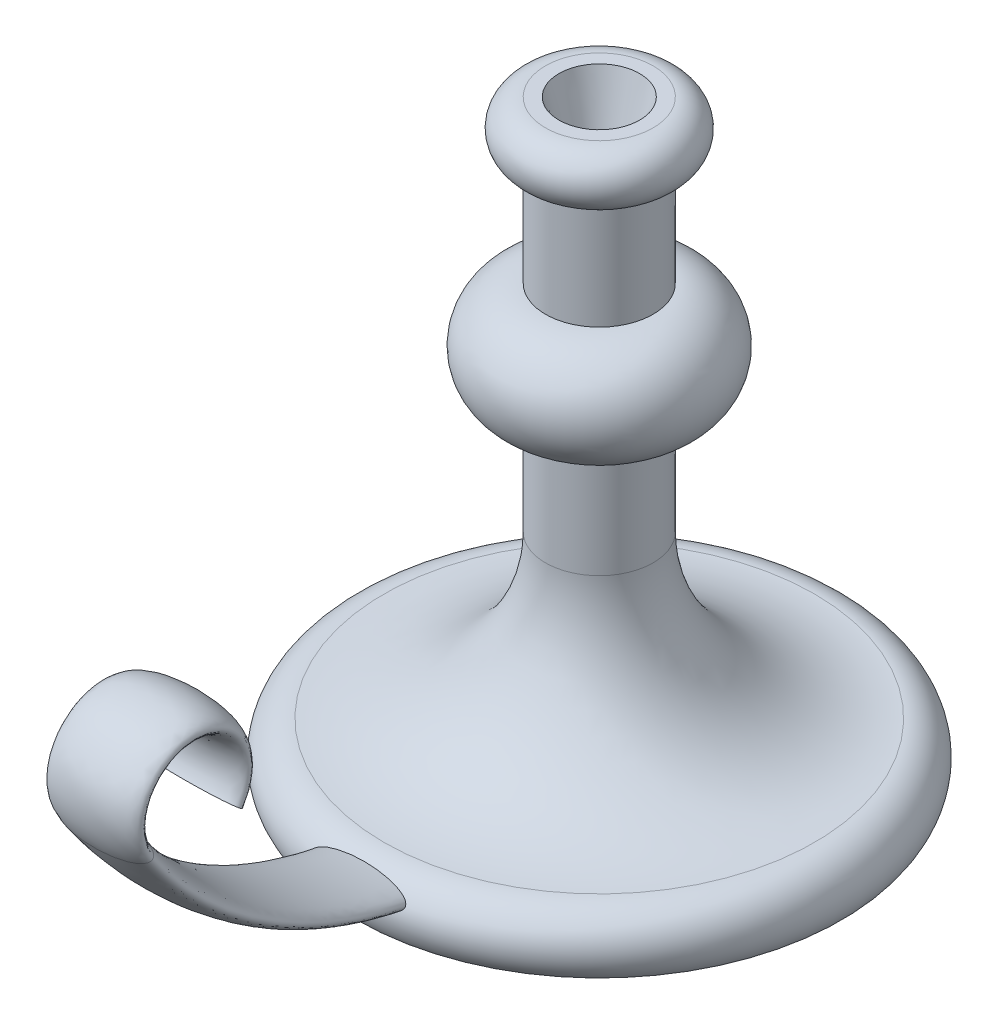
from build123d import *

# Parameters (mm, degrees)
SKETCH9_RX         = 17.5
SKETCH9_RY         = 5
SKETCH18_R         = 15
CUT_EXTRUDE1_DEPTH = 25
CUT_EXTRUDE1_TAPER = 15


with BuildPart() as part:
    # Sketch3 → Revolve1 (revolve)
    with BuildSketch(Plane.XY):
        with BuildLine():
            Line((0, 0), (0, 220))
            Line((0, 220), (20, 220))
            ThreePointArc((20, 220), (30, 210), (20, 200))
            Line((20, 200), (20, 160))
            ThreePointArc((20, 160), (40, 140), (20, 120))
            Line((20, 120), (20, 80))
            ThreePointArc((20, 80), (37.573593129, 37.573593129), (80, 20))
            ThreePointArc((80, 20), (91.180339887, 13.090169944), (90, 0))
            Line((90, 0), (0, 0))
        make_face()
    revolve(axis=Axis((0, 0, 0), (0, 1, 0)))

    # Sweep2: sweep along a path in Sketch8
    with BuildLine(Plane(origin=(0, 0, 0), x_dir=(0, 0, -1), z_dir=(1, 0, 0))) as sweep2_path:
        Line((0, 10), (-60, 10))
        ThreePointArc((-60, 10), (-129.821200219, 27.240819526), (-183.592070943, 75))
        ThreePointArc((-183.592070943, 75), (-167.113128151, 106.333333333), (-150.634185358, 75))
    # Sketch9 → Sweep2 (sweep)
    with BuildSketch(Plane.XY):
        with Locations((0, 10)):
            Ellipse(SKETCH9_RX, SKETCH9_RY)
    sweep(path=sweep2_path.line)

    # Sketch18 → Cut-Extrude1 (cut)
    with BuildSketch(Plane(origin=(0, 220, 0), x_dir=(1, 0, 0), z_dir=(0, 1, 0))):
        Circle(SKETCH18_R)
    extrude(amount=-CUT_EXTRUDE1_DEPTH, taper=CUT_EXTRUDE1_TAPER, mode=Mode.SUBTRACT)


solid = part.part
